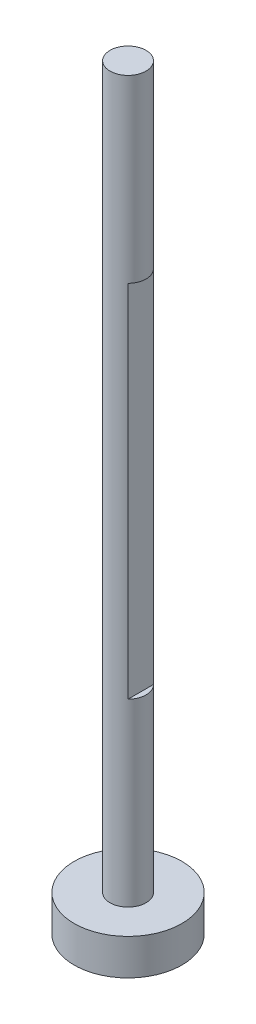
from build123d import *

# Parameters (mm, degrees)
SKETCH1_R           = 3.175
BOSS_EXTRUDE1_DEPTH = 127
CUT_EXTRUDE1_START  = -31.75
SKETCH2_W           = 1.117822334
SKETCH2_H           = 4.49012806
CUT_EXTRUDE1_DEPTH  = 63.5
SKETCH3_R           = 9.5
BOSS_EXTRUDE2_DEPTH = 6.35


with BuildPart() as part:
    # Sketch1 → Boss-Extrude1 (new body)
    with BuildSketch(Plane(origin=(0, 0, 0), x_dir=(1, 0, 0), z_dir=(0, 1, 0))):
        Circle(SKETCH1_R)
    extrude(amount=BOSS_EXTRUDE1_DEPTH)

    # Sketch2 → Cut-Extrude1 (cut)
    with BuildSketch(Plane.XZ.offset(CUT_EXTRUDE1_START)):
        with Locations((2.803975197, 0)):
            Rectangle(SKETCH2_W, SKETCH2_H)
    extrude(amount=-CUT_EXTRUDE1_DEPTH, mode=Mode.SUBTRACT)

    # Sketch3 → Boss-Extrude2 (add)
    with BuildSketch(Plane.XZ):
        Circle(SKETCH3_R)
    extrude(amount=BOSS_EXTRUDE2_DEPTH)


solid = part.part
